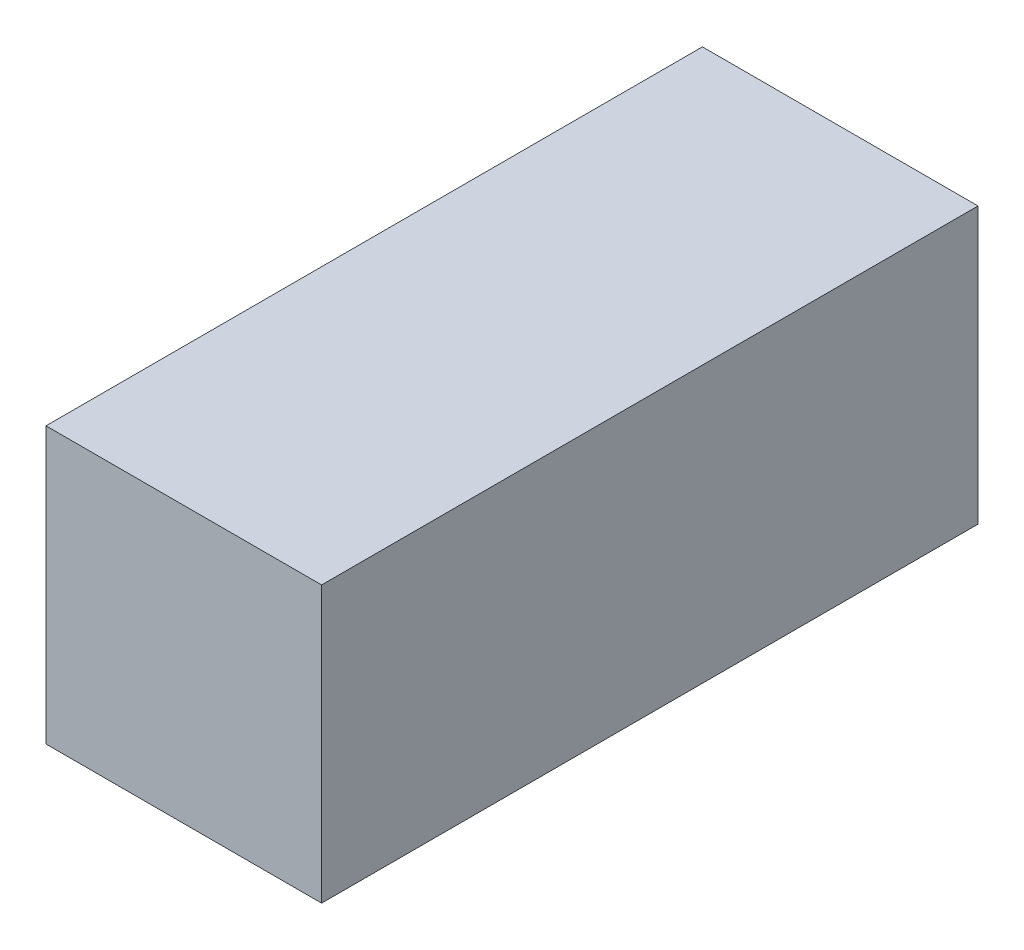
from build123d import *

# Parameters (mm, degrees)
SCHIZZO1_W                   = 67.175144212
SCHIZZO1_H                   = 67.175144212
ESTRUSIONE_ESTRUSIONE1_DEPTH = 160


with BuildPart() as part:
    # Schizzo1 → Estrusione-Estrusione1 (new body)
    with BuildSketch(Plane.XY):
        Rectangle(SCHIZZO1_W, SCHIZZO1_H)
    extrude(amount=ESTRUSIONE_ESTRUSIONE1_DEPTH)


solid = part.part
